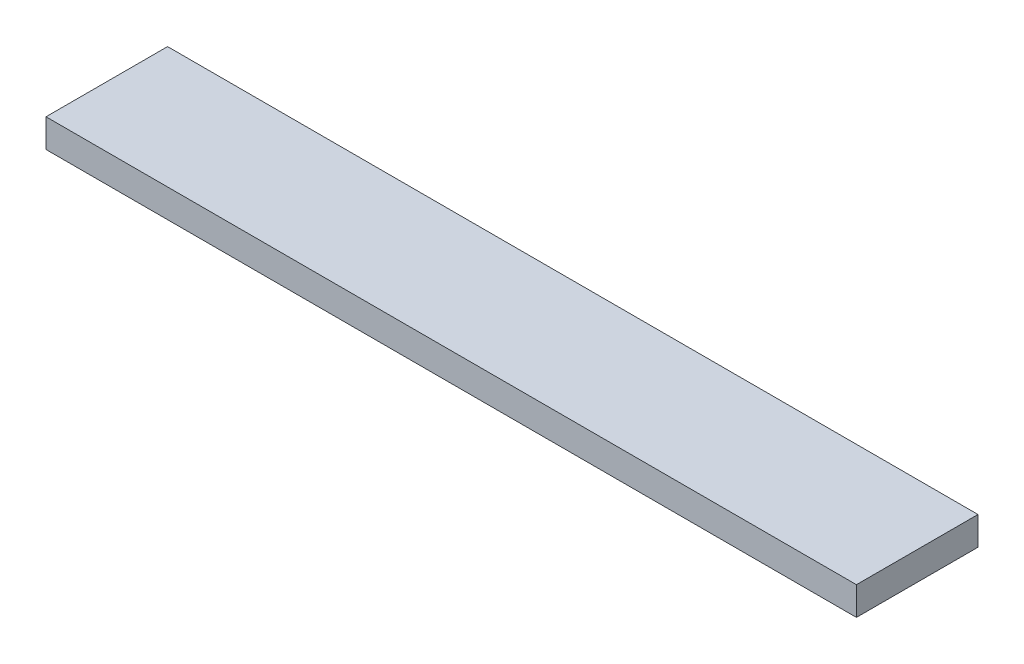
from build123d import *

# Parameters (mm, degrees)
SKETCH1_W           = 1000
SKETCH1_H           = 35
BOSS_EXTRUDE1_DEPTH = 150


with BuildPart() as part:
    # Sketch1 → Boss-Extrude1 (new body)
    with BuildSketch(Plane.XY):
        Rectangle(SKETCH1_W, SKETCH1_H)
    extrude(amount=BOSS_EXTRUDE1_DEPTH)


solid = part.part
